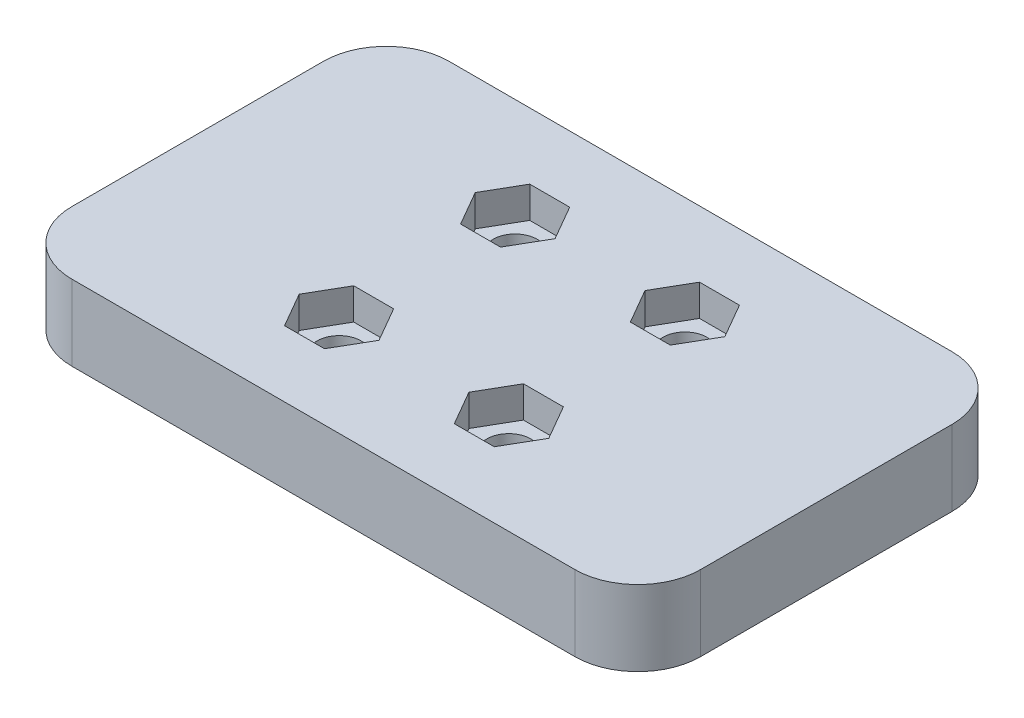
from build123d import *

# Parameters (mm, degrees)
SKETCH1_R           = 1.75
BOSS_EXTRUDE1_DEPTH = 6
CUT_EXTRUDE1_DEPTH  = 2.5
BOSS_EXTRUDE2_DEPTH = 6


with BuildPart() as part:
    # Sketch1 → Boss-Extrude1 (new body)
    with BuildSketch(Plane(origin=(0, 0, 0), x_dir=(1, 0, 0), z_dir=(0, 1, 0))):
        with BuildLine():
            Line((5, 0), (45, 0))
            ThreePointArc((45, 0), (48.535533906, 1.464466094), (50, 5))
            Line((50, 5), (50, 10))
            ThreePointArc((50, 10), (48.535533906, 13.535533906), (45, 15))
            Line((45, 15), (5, 15))
            ThreePointArc((5, 15), (1.464466094, 13.535533906), (0, 10))
            Line((0, 10), (0, 5))
            ThreePointArc((0, 5), (1.464466094, 1.464466094), (5, 0))
        make_face()
        with Locations((18.25, 7)):
            Circle(SKETCH1_R, mode=Mode.SUBTRACT)
        with Locations((31.75, 7)):
            Circle(SKETCH1_R, mode=Mode.SUBTRACT)
    boss_extrude1 = extrude(amount=BOSS_EXTRUDE1_DEPTH)

    # Sketch2 → Cut-Extrude1 (cut)
    with BuildSketch(Plane(origin=(0, 6, 0), x_dir=(1, 0, 0), z_dir=(0, 1, 0))):
        Polygon((19.83771324, 4.25), (21.425426481, 7), (19.83771324, 9.75), (16.66228676, 9.75), (15.074573519, 7), (16.66228676, 4.25), align=None)
        Polygon((33.33771324, 4.25), (34.925426481, 7), (33.33771324, 9.75), (30.16228676, 9.75), (28.574573519, 7), (30.16228676, 4.25), align=None)
    cut_extrude1 = extrude(amount=-CUT_EXTRUDE1_DEPTH, mode=Mode.SUBTRACT)

    # Mirror1: Boss-Extrude1, Cut-Extrude1 across plane
    add(boss_extrude1.mirror(Plane.XY))
    add(cut_extrude1.mirror(Plane.XY), mode=Mode.SUBTRACT)

    # Sketch3 → Boss-Extrude2 (add)
    with BuildSketch(Plane(origin=(0, 6, 0), x_dir=(1, 0, 0), z_dir=(0, 1, 0))):
        with BuildLine():
            Line((50, 5), (50, -5))
            ThreePointArc((50, -5), (48.535533906, -1.464466094), (45, 0))
            ThreePointArc((45, 0), (48.535533906, 1.464466094), (50, 5))
        make_face()
        with BuildLine():
            Line((0, 5), (0, -5))
            ThreePointArc((0, -5), (1.464466094, -1.464466094), (5, 0))
            ThreePointArc((5, 0), (1.464466094, 1.464466094), (0, 5))
        make_face()
    extrude(amount=-BOSS_EXTRUDE2_DEPTH)


solid = part.part
